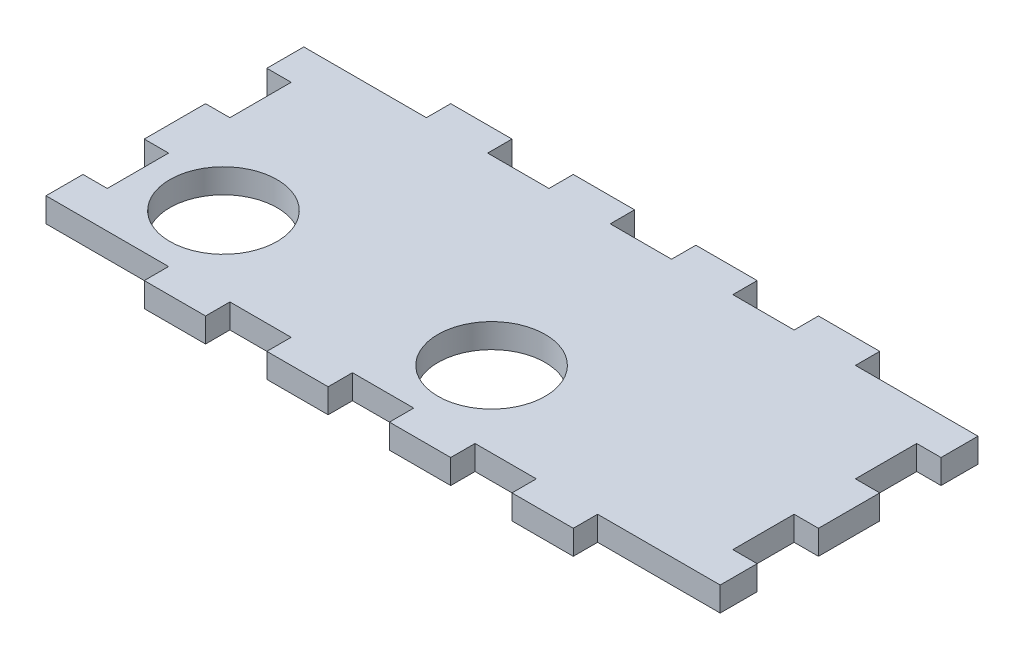
from build123d import *

# Parameters (mm, degrees)
SKETCH1_W           = 88
SKETCH1_H           = 40
BOSS_EXTRUDE1_DEPTH = 3.175
CUT_EXTRUDE1_REACH  = 5.175
SKETCH2_W           = 16
SKETCH2_H           = 3.175
SKETCH2_W_2         = 8
CUT_EXTRUDE2_REACH  = 5.175
SKETCH3_W           = 3.175
SKETCH3_H           = 8
CUT_EXTRUDE3_REACH  = 5.175
SKETCH4_R           = 7


with BuildPart() as part:
    # Sketch1 → Boss-Extrude1 (new body)
    with BuildSketch(Plane(origin=(0, 0, 0), x_dir=(1, 0, 0), z_dir=(0, 1, 0))):
        with Locations((44, -20)):
            Rectangle(SKETCH1_W, SKETCH1_H)
    extrude(amount=BOSS_EXTRUDE1_DEPTH)

    # Sketch2 → Cut-Extrude1 (cut, up to next)
    with BuildSketch(Plane(origin=(0, 3.175, 0), x_dir=(1, 0, 0), z_dir=(0, 1, 0)), mode=Mode.PRIVATE) as cut_extrude1_sk1:
        with Locations((8, -1.5875)):
            Rectangle(SKETCH2_W, SKETCH2_H)
    cut_extrude1_tool1 = extrude(cut_extrude1_sk1.sketch, amount=-CUT_EXTRUDE1_REACH, mode=Mode.PRIVATE) & part.part
    add(cut_extrude1_tool1.solids().sort_by_distance((8, 3.175, 1.5875))[0], mode=Mode.SUBTRACT)
    # Sketch2 → Cut-Extrude1 (cut, up to next)
    with BuildSketch(Plane(origin=(0, 3.175, 0), x_dir=(1, 0, 0), z_dir=(0, 1, 0)), mode=Mode.PRIVATE) as cut_extrude1_sk2:
        with Locations((44, -1.5875)):
            Rectangle(SKETCH2_W_2, SKETCH2_H)
    cut_extrude1_tool2 = extrude(cut_extrude1_sk2.sketch, amount=-CUT_EXTRUDE1_REACH, mode=Mode.PRIVATE) & part.part
    add(cut_extrude1_tool2.solids().sort_by_distance((44, 3.175, 1.5875))[0], mode=Mode.SUBTRACT)
    # Sketch2 → Cut-Extrude1 (cut, up to next)
    with BuildSketch(Plane(origin=(0, 3.175, 0), x_dir=(1, 0, 0), z_dir=(0, 1, 0)), mode=Mode.PRIVATE) as cut_extrude1_sk3:
        with Locations((60, -1.5875)):
            Rectangle(SKETCH2_W_2, SKETCH2_H)
    cut_extrude1_tool3 = extrude(cut_extrude1_sk3.sketch, amount=-CUT_EXTRUDE1_REACH, mode=Mode.PRIVATE) & part.part
    add(cut_extrude1_tool3.solids().sort_by_distance((60, 3.175, 1.5875))[0], mode=Mode.SUBTRACT)
    # Sketch2 → Cut-Extrude1 (cut, up to next)
    with BuildSketch(Plane(origin=(0, 3.175, 0), x_dir=(1, 0, 0), z_dir=(0, 1, 0)), mode=Mode.PRIVATE) as cut_extrude1_sk4:
        with Locations((80, -1.5875)):
            Rectangle(SKETCH2_W, SKETCH2_H)
    cut_extrude1_tool4 = extrude(cut_extrude1_sk4.sketch, amount=-CUT_EXTRUDE1_REACH, mode=Mode.PRIVATE) & part.part
    add(cut_extrude1_tool4.solids().sort_by_distance((80, 3.175, 1.5875))[0], mode=Mode.SUBTRACT)
    # Sketch2 → Cut-Extrude1 (cut, up to next)
    with BuildSketch(Plane(origin=(0, 3.175, 0), x_dir=(1, 0, 0), z_dir=(0, 1, 0)), mode=Mode.PRIVATE) as cut_extrude1_sk5:
        with Locations((28, -1.5875)):
            Rectangle(SKETCH2_W_2, SKETCH2_H)
    cut_extrude1_tool5 = extrude(cut_extrude1_sk5.sketch, amount=-CUT_EXTRUDE1_REACH, mode=Mode.PRIVATE) & part.part
    add(cut_extrude1_tool5.solids().sort_by_distance((28, 3.175, 1.5875))[0], mode=Mode.SUBTRACT)
    # Sketch2 → Cut-Extrude1 (cut, up to next)
    with BuildSketch(Plane(origin=(0, 3.175, 0), x_dir=(1, 0, 0), z_dir=(0, 1, 0)), mode=Mode.PRIVATE) as cut_extrude1_sk6:
        with Locations((44, -38.4125)):
            Rectangle(SKETCH2_W_2, SKETCH2_H)
    cut_extrude1_tool6 = extrude(cut_extrude1_sk6.sketch, amount=-CUT_EXTRUDE1_REACH, mode=Mode.PRIVATE) & part.part
    add(cut_extrude1_tool6.solids().sort_by_distance((44, 3.175, 38.4125))[0], mode=Mode.SUBTRACT)
    # Sketch2 → Cut-Extrude1 (cut, up to next)
    with BuildSketch(Plane(origin=(0, 3.175, 0), x_dir=(1, 0, 0), z_dir=(0, 1, 0)), mode=Mode.PRIVATE) as cut_extrude1_sk7:
        with Locations((28, -38.4125)):
            Rectangle(SKETCH2_W_2, SKETCH2_H)
    cut_extrude1_tool7 = extrude(cut_extrude1_sk7.sketch, amount=-CUT_EXTRUDE1_REACH, mode=Mode.PRIVATE) & part.part
    add(cut_extrude1_tool7.solids().sort_by_distance((28, 3.175, 38.4125))[0], mode=Mode.SUBTRACT)
    # Sketch2 → Cut-Extrude1 (cut, up to next)
    with BuildSketch(Plane(origin=(0, 3.175, 0), x_dir=(1, 0, 0), z_dir=(0, 1, 0)), mode=Mode.PRIVATE) as cut_extrude1_sk8:
        with Locations((8, -38.4125)):
            Rectangle(SKETCH2_W, SKETCH2_H)
    cut_extrude1_tool8 = extrude(cut_extrude1_sk8.sketch, amount=-CUT_EXTRUDE1_REACH, mode=Mode.PRIVATE) & part.part
    add(cut_extrude1_tool8.solids().sort_by_distance((8, 3.175, 38.4125))[0], mode=Mode.SUBTRACT)
    # Sketch2 → Cut-Extrude1 (cut, up to next)
    with BuildSketch(Plane(origin=(0, 3.175, 0), x_dir=(1, 0, 0), z_dir=(0, 1, 0)), mode=Mode.PRIVATE) as cut_extrude1_sk9:
        with Locations((80, -38.4125)):
            Rectangle(SKETCH2_W, SKETCH2_H)
    cut_extrude1_tool9 = extrude(cut_extrude1_sk9.sketch, amount=-CUT_EXTRUDE1_REACH, mode=Mode.PRIVATE) & part.part
    add(cut_extrude1_tool9.solids().sort_by_distance((80, 3.175, 38.4125))[0], mode=Mode.SUBTRACT)
    # Sketch2 → Cut-Extrude1 (cut, up to next)
    with BuildSketch(Plane(origin=(0, 3.175, 0), x_dir=(1, 0, 0), z_dir=(0, 1, 0)), mode=Mode.PRIVATE) as cut_extrude1_sk10:
        with Locations((60, -38.4125)):
            Rectangle(SKETCH2_W_2, SKETCH2_H)
    cut_extrude1_tool10 = extrude(cut_extrude1_sk10.sketch, amount=-CUT_EXTRUDE1_REACH, mode=Mode.PRIVATE) & part.part
    add(cut_extrude1_tool10.solids().sort_by_distance((60, 3.175, 38.4125))[0], mode=Mode.SUBTRACT)

    # Sketch3 → Cut-Extrude2 (cut, up to next)
    with BuildSketch(Plane(origin=(0, 3.175, 0), x_dir=(1, 0, 0), z_dir=(0, 1, 0)), mode=Mode.PRIVATE) as cut_extrude2_sk1:
        with Locations((1.5875, -28)):
            Rectangle(SKETCH3_W, SKETCH3_H)
    cut_extrude2_tool1 = extrude(cut_extrude2_sk1.sketch, amount=-CUT_EXTRUDE2_REACH, mode=Mode.PRIVATE) & part.part
    add(cut_extrude2_tool1.solids().sort_by_distance((1.5875, 3.175, 28))[0], mode=Mode.SUBTRACT)
    # Sketch3 → Cut-Extrude2 (cut, up to next)
    with BuildSketch(Plane(origin=(0, 3.175, 0), x_dir=(1, 0, 0), z_dir=(0, 1, 0)), mode=Mode.PRIVATE) as cut_extrude2_sk2:
        with Locations((1.5875, -12)):
            Rectangle(SKETCH3_W, SKETCH3_H)
    cut_extrude2_tool2 = extrude(cut_extrude2_sk2.sketch, amount=-CUT_EXTRUDE2_REACH, mode=Mode.PRIVATE) & part.part
    add(cut_extrude2_tool2.solids().sort_by_distance((1.5875, 3.175, 12))[0], mode=Mode.SUBTRACT)
    # Sketch3 → Cut-Extrude2 (cut, up to next)
    with BuildSketch(Plane(origin=(0, 3.175, 0), x_dir=(1, 0, 0), z_dir=(0, 1, 0)), mode=Mode.PRIVATE) as cut_extrude2_sk3:
        with Locations((86.4125, -28)):
            Rectangle(SKETCH3_W, SKETCH3_H)
    cut_extrude2_tool3 = extrude(cut_extrude2_sk3.sketch, amount=-CUT_EXTRUDE2_REACH, mode=Mode.PRIVATE) & part.part
    add(cut_extrude2_tool3.solids().sort_by_distance((86.4125, 3.175, 28))[0], mode=Mode.SUBTRACT)
    # Sketch3 → Cut-Extrude2 (cut, up to next)
    with BuildSketch(Plane(origin=(0, 3.175, 0), x_dir=(1, 0, 0), z_dir=(0, 1, 0)), mode=Mode.PRIVATE) as cut_extrude2_sk4:
        with Locations((86.4125, -12)):
            Rectangle(SKETCH3_W, SKETCH3_H)
    cut_extrude2_tool4 = extrude(cut_extrude2_sk4.sketch, amount=-CUT_EXTRUDE2_REACH, mode=Mode.PRIVATE) & part.part
    add(cut_extrude2_tool4.solids().sort_by_distance((86.4125, 3.175, 12))[0], mode=Mode.SUBTRACT)

    # Sketch4 → Cut-Extrude3 (cut, up to next)
    with BuildSketch(Plane(origin=(0, 3.175, 0), x_dir=(1, 0, 0), z_dir=(0, 1, 0)), mode=Mode.PRIVATE) as cut_extrude3_sk1:
        with Locations((13.25, -26.915)):
            Circle(SKETCH4_R)
    cut_extrude3_tool1 = extrude(cut_extrude3_sk1.sketch, amount=-CUT_EXTRUDE3_REACH, mode=Mode.PRIVATE) & part.part
    add(cut_extrude3_tool1.solids().sort_by_distance((13.25, 3.175, 26.915))[0], mode=Mode.SUBTRACT)
    # Sketch4 → Cut-Extrude3 (cut, up to next)
    with BuildSketch(Plane(origin=(0, 3.175, 0), x_dir=(1, 0, 0), z_dir=(0, 1, 0)), mode=Mode.PRIVATE) as cut_extrude3_sk2:
        with Locations((48.25, -26.915)):
            Circle(SKETCH4_R)
    cut_extrude3_tool2 = extrude(cut_extrude3_sk2.sketch, amount=-CUT_EXTRUDE3_REACH, mode=Mode.PRIVATE) & part.part
    add(cut_extrude3_tool2.solids().sort_by_distance((48.25, 3.175, 26.915))[0], mode=Mode.SUBTRACT)


solid = part.part
